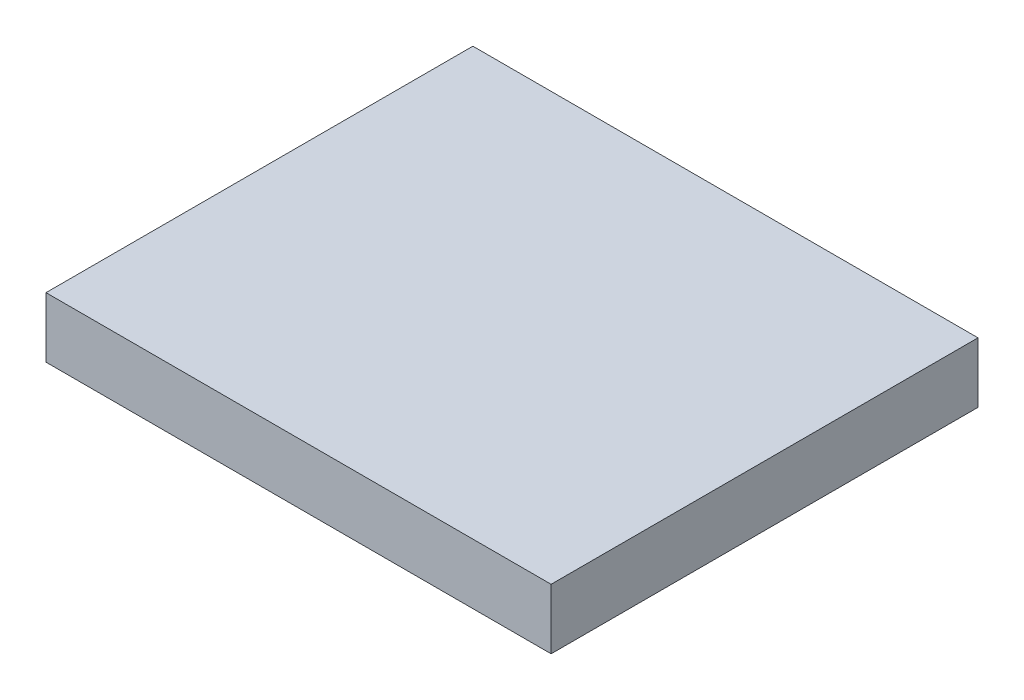
from build123d import *

# Parameters (mm, degrees)
SKETCH1_W                = 1156.126069877
SKETCH1_H                = 163.121844074
BOSS_EXTRUDE1_DEPTH      = 776
BOSS_EXTRUDE1_DEPTH_BACK = 592


with BuildPart() as part:
    # Sketch1 → Boss-Extrude1 (new body, two sides)
    with BuildSketch(Plane(origin=(-6.949111765, -0.000555745, -100.47405685), x_dir=(0, 0, -1), z_dir=(1, 0, 0))) as boss_extrude1_sk:
        with Locations((-109.558471861, 244.964930534)):
            Rectangle(SKETCH1_W, SKETCH1_H)
    extrude(amount=BOSS_EXTRUDE1_DEPTH)
    extrude(boss_extrude1_sk.sketch, amount=-BOSS_EXTRUDE1_DEPTH_BACK)


solid = part.part
